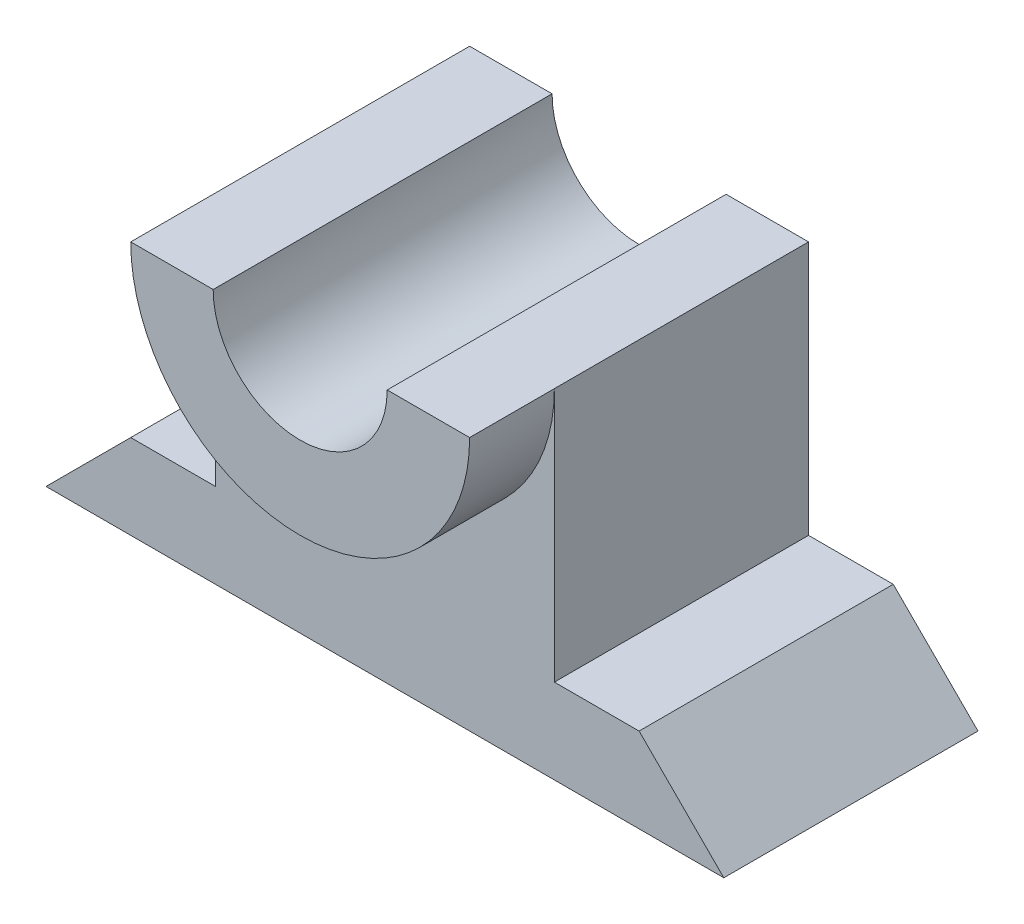
from build123d import *

# Parameters (mm, degrees)
BOSS_EXTRUDE1_DEPTH = 762
BOSS_EXTRUDE2_DEPTH = 1016


with BuildPart() as part:
    # Sketch1 → Boss-Extrude1 (new body)
    with BuildSketch(Plane.XY):
        with BuildLine():
            ThreePointArc((508, 0), (0, -508), (-508, 0))
            Line((-508, 0), (-508, -762))
            Line((-508, -762), (-762, -762))
            Line((-762, -762), (-1016, -1016))
            Line((-1016, -1016), (1016, -1016))
            Line((1016, -1016), (762, -762))
            Line((762, -762), (508, -762))
            Line((508, -762), (508, 0))
        make_face()
    extrude(amount=BOSS_EXTRUDE1_DEPTH)

    # Sketch1_3 → Boss-Extrude2 (add)
    with BuildSketch(Plane.XY):
        with BuildLine():
            ThreePointArc((260.853189007, 0), (0, -260.853189007), (-260.853189007, 0))
            Line((-260.853189007, 0), (-508, 0))
            ThreePointArc((-508, 0), (0, -508), (508, 0))
            Line((508, 0), (260.853189007, 0))
        make_face()
    extrude(amount=BOSS_EXTRUDE2_DEPTH)


solid = part.part
